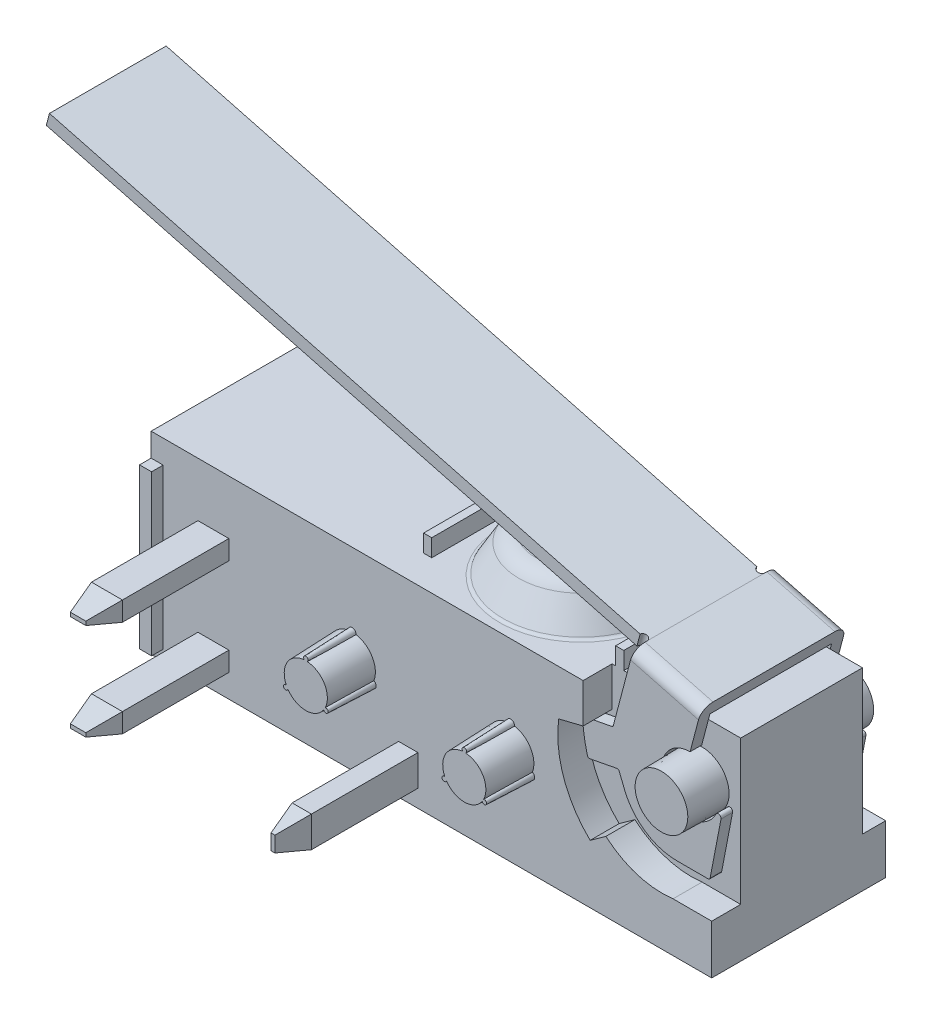
from build123d import *

# Parameters (mm, degrees)
BOSS_EXTRUDE1_DEPTH           = 4.5
BOSS_EXTRUDE3_DEPTH           = 1.2
BOSS_EXTRUDE3_DRAFT           = 2
BOSS_EXTRUDE3_PROFILE_2_DEPTH = 1.2
BOSS_EXTRUDE3_PROFILE_2_DRAFT = 2
SKETCH3_W                     = 0.5
SKETCH3_H                     = 0.8
BOSS_EXTRUDE4_DEPTH           = 3.5
SKETCH3_W_2                   = 0.8
SKETCH3_H_2                   = 0.5
BOSS_EXTRUDE4_2_DEPTH         = 3.5
BOSS_EXTRUDE4_3_DEPTH         = 3.5
CHAMFER1_SIZE                 = 0.2
CHAMFER1_SIZE2                = 0.746410162
CHAMFER2_SIZE                 = 0.2
CHAMFER2_SIZE2                = 0.746410162
CHAMFER3_SIZE                 = 0.2
CHAMFER3_SIZE2                = 0.746410162
CUT_EXTRUDE1_DEPTH            = 0.75
SKETCH6_R                     = 0.7
BOSS_EXTRUDE6_DEPTH           = 1.05
BOSS_EXTRUDE6_TAPER           = 1
CUT_EXTRUDE2_DEPTH            = 0.6
SKETCH8_R                     = 0.7
BOSS_EXTRUDE7_DEPTH           = 0.6
BOSS_EXTRUDE7_TAPER           = 1
SKETCH9_R                     = 2.05
BOSS_EXTRUDE8_DEPTH           = 1
BOSS_EXTRUDE8_TAPER           = 30
FILLET1_R                     = 0.5
FILLET2_R                     = 0.1
SKETCH10_R                    = 0.8
CUT_EXTRUDE3_DEPTH            = 0.2
SKETCH11_R                    = 0.7
BOSS_EXTRUDE9_DEPTH           = 0.4
DOME1_FACE_RADIUS             = 0.7
DOME1_HEIGHT                  = 0.2
SKETCH12_W                    = 0.21
SKETCH12_H                    = 3.15
BOSS_EXTRUDE10_DEPTH          = 0.45
SKETCH14_W                    = 0.311324836
SKETCH14_H                    = 4.124707826
BOSS_EXTRUDE11_DEPTH          = 0.3
BOSS_EXTRUDE12_DEPTH          = 0.3
LPATTERN1_COUNT               = 2
LPATTERN1_PITCH               = 3.45
BOSS_EXTRUDE13_DEPTH          = 3.15
SKETCH18_W                    = 3.75
SKETCH18_H                    = 0.32
BOSS_EXTRUDE14_DEPTH          = 16
CUT_EXTRUDE4_DEPTH            = 0.32
FILLET3_R                     = 0.3


with BuildPart() as part:
    # Sketch1 → Boss-Extrude1 (new body)
    with BuildSketch(Plane.XY):
        Polygon((0, -2.5), (5.2, -2.5), (5.2, 2.5), (-9.3, 2.5), (-9.3, -2.5), align=None)
    extrude(amount=-BOSS_EXTRUDE1_DEPTH)


with BuildPart() as boss_extrude3_tool:
    # Sketch2 → Boss-Extrude3 (with draft: the straight prism first)
    with BuildSketch(Plane.XY):
        with BuildLine():
            ThreePointArc((-0.099652173, 0.591666667), (-0.519615242, 0.3), (-0.56222445, -0.20953202))
            ThreePointArc((-0.56222445, -0.20953202), (-0.606217783, -0.35), (-0.462572277, -0.382134647))
            ThreePointArc((-0.462572277, -0.382134647), (0, -0.6), (0.462572277, -0.382134647))
            ThreePointArc((0.462572277, -0.382134647), (0.606217783, -0.35), (0.56222445, -0.20953202))
            ThreePointArc((0.56222445, -0.20953202), (0.519615242, 0.3), (0.099652173, 0.591666667))
            ThreePointArc((0.099652173, 0.591666667), (0, 0.7), (-0.099652173, 0.591666667))
        make_face()
    extrude(amount=BOSS_EXTRUDE3_DEPTH)
    # Boss-Extrude3: the draft: its side faces are tilted about the plane it starts from
    boss_extrude3_sides = [boss_extrude3_tool.faces().sort_by_distance(p)[0] for p in [
        (0.519615242, 0.3, 0.6),
        (0, 0.7, 0.6),
        (-0.519615242, 0.3, 0.6),
        (-0.606217783, -0.35, 0.6),
        (0, -0.6, 0.6),
        (0.606217783, -0.35, 0.6),
    ]]
    draft(boss_extrude3_sides, Plane.XY, BOSS_EXTRUDE3_DRAFT)


with BuildPart() as part_1:
    add(part.part)

    # Boss-Extrude3: add boss_extrude3_tool
    add(boss_extrude3_tool.part)


with BuildPart() as boss_extrude3_profile_2_tool:
    # Sketch2 → Boss-Extrude3 profile 2 (with draft: the straight prism first)
    with BuildSketch(Plane.XY):
        with BuildLine():
            ThreePointArc((-4.66222445, -0.20953202), (-4.706217783, -0.35), (-4.562572277, -0.382134647))
            ThreePointArc((-4.562572277, -0.382134647), (-4.1, -0.6), (-3.637427723, -0.382134647))
            ThreePointArc((-3.637427723, -0.382134647), (-3.493782217, -0.35), (-3.53777555, -0.20953202))
            ThreePointArc((-3.53777555, -0.20953202), (-3.580384758, 0.3), (-4.000347827, 0.591666667))
            ThreePointArc((-4.000347827, 0.591666667), (-4.1, 0.7), (-4.199652173, 0.591666667))
            ThreePointArc((-4.199652173, 0.591666667), (-4.619615242, 0.3), (-4.66222445, -0.20953202))
        make_face()
    extrude(amount=BOSS_EXTRUDE3_PROFILE_2_DEPTH)
    # Boss-Extrude3 profile 2: the draft: its side faces are tilted about the plane it starts from
    boss_extrude3_profile_2_sides = [boss_extrude3_profile_2_tool.faces().sort_by_distance(p)[0] for p in [
        (-4.1, 0.7, 0.6),
        (-4.619615242, 0.3, 0.6),
        (-4.706217783, -0.35, 0.6),
        (-4.1, -0.6, 0.6),
        (-3.493782217, -0.35, 0.6),
        (-3.580384758, 0.3, 0.6),
    ]]
    draft(boss_extrude3_profile_2_sides, Plane.XY, BOSS_EXTRUDE3_PROFILE_2_DRAFT)


with BuildPart() as part_2:
    add(part_1.part)

    # Boss-Extrude3 profile 2: add boss_extrude3_profile_2_tool
    add(boss_extrude3_profile_2_tool.part)

    # Sketch5 → Cut-Extrude1 (cut)
    with BuildSketch(Plane.XY):
        with BuildLine():
            Line((5.2, 2.5), (1.873674348, 2.5))
            Line((1.873674348, 2.5), (1.873674348, 1.481625468))
            Line((1.873674348, 1.481625468), (1.241954315, 1.325609641))
            ThreePointArc((1.241954315, 1.325609641), (1.37112217, 0.071098566), (2.055446922, -0.988232357))
            Line((2.055446922, -0.988232357), (2.46319838, -0.695622678))
            ThreePointArc((2.46319838, -0.695622678), (3.274611315, -1.147475163), (4.2, -1.226325652))
            Line((4.2, -1.226325652), (5.2, -1.226325652))
            Line((5.2, -1.226325652), (5.2, 2.5))
        make_face()
    extrude(amount=-CUT_EXTRUDE1_DEPTH, mode=Mode.SUBTRACT)

    # Sketch6 → Boss-Extrude6 (add)
    with BuildSketch(Plane.XY.offset(-0.75)):
        with Locations((4.2, 1.1)):
            Circle(SKETCH6_R)
    extrude(amount=BOSS_EXTRUDE6_DEPTH, taper=BOSS_EXTRUDE6_TAPER)

    # Sketch7 → Cut-Extrude2 (cut)
    with BuildSketch(Plane(origin=(0, 0, -4.5), x_dir=(-1, 0, 0), z_dir=(0, 0, -1))):
        with BuildLine():
            Line((-1.274940789, 1.291908081), (-1.873674348, 1.453118443))
            Line((-1.873674348, 1.453118443), (-1.873674348, 2.5))
            Line((-1.873674348, 2.5), (-5.2, 2.5))
            Line((-5.2, 2.5), (-5.2, -1.226325652))
            Line((-5.2, -1.226325652), (-4.2, -1.226325652))
            ThreePointArc((-4.2, -1.226325652), (-3.274611315, -1.147475163), (-2.46319838, -0.695622678))
            Line((-2.46319838, -0.695622678), (-2.086048236, -0.966272312))
            ThreePointArc((-2.086048236, -0.966272312), (-1.41206126, 0.06640034), (-1.274940789, 1.291908081))
        make_face()
    extrude(amount=-CUT_EXTRUDE2_DEPTH, mode=Mode.SUBTRACT)

    # Sketch8 → Boss-Extrude7 (add)
    with BuildSketch(Plane(origin=(0, 0, -3.9), x_dir=(-1, 0, 0), z_dir=(0, 0, -1))):
        with Locations((-4.2, 1.1)):
            Circle(SKETCH8_R)
    extrude(amount=BOSS_EXTRUDE7_DEPTH, taper=BOSS_EXTRUDE7_TAPER)

    # Sketch9 → Boss-Extrude8 (add)
    with BuildSketch(Plane(origin=(0, 2.5, 0), x_dir=(1, 0, 0), z_dir=(0, 1, 0))):
        with Locations((-0.5, 2.325)):
            Circle(SKETCH9_R)
    extrude(amount=BOSS_EXTRUDE8_DEPTH, taper=BOSS_EXTRUDE8_TAPER)

    # Fillet1
    fillet1_edges = [part_2.edges().sort_by_distance(p)[0] for p in [
        (-1.972649731, 3.5, -2.325),
    ]]
    fillet(fillet1_edges, radius=FILLET1_R)

    # Fillet2
    fillet2_edges = [part_2.edges().sort_by_distance(p)[0] for p in [
        (-2.55, 2.5, -2.325),
    ]]
    fillet(fillet2_edges, radius=FILLET2_R)

    # Sketch10 → Cut-Extrude3 (cut)
    with BuildSketch(Plane(origin=(0, 3.5, 0), x_dir=(1, 0, 0), z_dir=(0, 1, 0))):
        with Locations(Location((-0.5, 2.325, 0), (0, 0, 180))):
            Circle(SKETCH10_R)
    extrude(amount=-CUT_EXTRUDE3_DEPTH, mode=Mode.SUBTRACT)

    # Sketch11 → Boss-Extrude9 (add)
    with BuildSketch(Plane(origin=(0, 3.3, 0), x_dir=(1, 0, 0), z_dir=(0, 1, 0))):
        with Locations(Location((-0.5, 2.325, 0), (0, 0, 180))):
            Circle(SKETCH11_R)
    extrude(amount=BOSS_EXTRUDE9_DEPTH)

    # Dome1: a dome of height H over a round flat face of radius A is a cap of a sphere of radius (A * A + H * H) / (2 * H)
    dome1_r = (DOME1_FACE_RADIUS * DOME1_FACE_RADIUS + DOME1_HEIGHT * DOME1_HEIGHT) / (2 * DOME1_HEIGHT)
    dome1_base = Plane((-0.5, 3.7, -2.325), z_dir=(0, 1, 0))
    with Locations(dome1_base.offset(DOME1_HEIGHT - dome1_r)):
        dome1_ball = Sphere(dome1_r, mode=Mode.PRIVATE)
    add(split(dome1_ball, bisect_by=dome1_base, keep=Keep.TOP, mode=Mode.PRIVATE))

    # Sketch12 → Boss-Extrude10 (add)
    with BuildSketch(Plane(origin=(0, 2.5, 0), x_dir=(1, 0, 0), z_dir=(0, 1, 0))):
        with Locations((2.07034832, 2.325)):
            Rectangle(SKETCH12_W, SKETCH12_H)
        with Locations((-2.93965168, 2.366987298)):
            Rectangle(SKETCH12_W, SKETCH12_H)
    extrude(amount=BOSS_EXTRUDE10_DEPTH)

    # Sketch14 → Boss-Extrude11 (add)
    with BuildSketch(Plane.XY):
        with Locations((-9.144337582, -0.166601739)):
            Rectangle(SKETCH14_W, SKETCH14_H)
    extrude(amount=BOSS_EXTRUDE11_DEPTH)


with BuildPart() as body_2:
    # Sketch3 → Boss-Extrude4 (new body)
    with BuildSketch(Plane.XY):
        with Locations((-2.65, -1.65)):
            Rectangle(SKETCH3_W, SKETCH3_H)
    extrude(amount=BOSS_EXTRUDE4_DEPTH)

    # Chamfer1
    chamfer1_edges = [body_2.edges().sort_by_distance(p)[0] for p in [
        (-2.4, -1.65, 3.5),
        (-2.65, -1.25, 3.5),
        (-2.9, -1.65, 3.5),
        (-2.65, -2.05, 3.5),
    ]]
    chamfer1_side = [body_2.faces().sort_by_distance(p)[0] for p in [
        (-2.65, -1.65, 3.5),
    ]]
    chamfer(chamfer1_edges, length=CHAMFER1_SIZE, length2=CHAMFER1_SIZE2, reference=chamfer1_side[0])


with BuildPart() as body_3:
    # Sketch3 → Boss-Extrude4 2 (new body)
    with BuildSketch(Plane.XY):
        with Locations((-7.69, -1.65)):
            Rectangle(SKETCH3_W_2, SKETCH3_H_2)
    extrude(amount=BOSS_EXTRUDE4_2_DEPTH)

    # Chamfer3
    chamfer3_edges = [body_3.edges().sort_by_distance(p)[0] for p in [
        (-7.69, -1.4, 3.5),
        (-8.09, -1.65, 3.5),
        (-7.69, -1.9, 3.5),
        (-7.29, -1.65, 3.5),
    ]]
    chamfer3_side = [body_3.faces().sort_by_distance(p)[0] for p in [
        (-7.69, -1.65, 3.5),
    ]]
    chamfer(chamfer3_edges, length=CHAMFER3_SIZE, length2=CHAMFER3_SIZE2, reference=chamfer3_side[0])


with BuildPart() as body_4:
    # Sketch3 → Boss-Extrude4 3 (new body)
    with BuildSketch(Plane.XY):
        with Locations((-7.69, 0.85)):
            Rectangle(SKETCH3_W_2, SKETCH3_H_2)
    extrude(amount=BOSS_EXTRUDE4_3_DEPTH)

    # Chamfer2
    chamfer2_edges = [body_4.edges().sort_by_distance(p)[0] for p in [
        (-7.69, 1.1, 3.5),
        (-8.09, 0.85, 3.5),
        (-7.69, 0.6, 3.5),
        (-7.29, 0.85, 3.5),
    ]]
    chamfer2_side = [body_4.faces().sort_by_distance(p)[0] for p in [
        (-7.69, 0.85, 3.5),
    ]]
    chamfer(chamfer2_edges, length=CHAMFER2_SIZE, length2=CHAMFER2_SIZE2, reference=chamfer2_side[0])


with BuildPart() as body_5:
    # Sketch16 → Boss-Extrude12 (new body)
    with BuildSketch(Plane(origin=(0, 0, -3.9), x_dir=(-1, 0, 0), z_dir=(0, 0, -1))):
        with BuildLine():
            Line((-2.72663653, 3.413925414), (-2.695824269, 3.296907977))
            Line((-2.695824269, 3.296907977), (-2.488472864, 2.50943572))
            Line((-2.488472864, 2.50943572), (-2.20425473, 1.430051227))
            ThreePointArc((-2.20425473, 1.430051227), (-2.189921217, 1.406051159), (-2.165005418, 1.39337615))
            Line((-2.165005418, 1.39337615), (-1.447969658, 1.255711923))
            ThreePointArc((-1.447969658, 1.255711923), (-1.417524264, 1.236952921), (-1.407177653, 1.202721797))
            ThreePointArc((-1.407177653, 1.202721797), (-1.45311078, 0.809028192), (-1.53591297, 0.421409431))
            ThreePointArc((-1.53591297, 0.421409431), (-1.557811612, 0.391583969), (-1.594174631, 0.384740023))
            Line((-1.594174631, 0.384740023), (-2.299234869, 0.520103434))
            ThreePointArc((-2.299234869, 0.520103434), (-2.3328806, 0.514852457), (-2.35551456, 0.489410133))
            Line((-2.35551456, 0.489410133), (-2.495754598, 0.140912844))
            ThreePointArc((-2.495754598, 0.140912844), (-3.031478288, -0.524518255), (-3.848195145, -0.775061653))
            Line((-3.848195145, -0.775061653), (-4.65874421, -0.775061653))
            ThreePointArc((-4.65874421, -0.775061653), (-4.690850708, -0.763517251), (-4.708254225, -0.734170735))
            Line((-4.708254225, -0.734170735), (-4.990094107, 0.730319368))
            ThreePointArc((-4.990094107, 0.730319368), (-4.951140876, 0.8081036), (-4.865921819, 0.790626376))
            ThreePointArc((-4.865921819, 0.790626376), (-3.568066632, 0.696612208), (-4.191345891, 1.838886132))
            Line((-4.191345891, 1.838886132), (-4.367910647, 2.509435719))
            Line((-4.367910647, 2.509435719), (-4.484213486, 2.951129352))
            Line((-4.484213486, 2.951129352), (-2.72663653, 3.413925414))
        make_face()
    boss_extrude12 = extrude(amount=BOSS_EXTRUDE12_DEPTH)


with BuildPart() as part_3:
    add(part_2.part)

    # LPattern1: Boss-Extrude12 ×2
    with Locations(*[(0, 0, i * LPATTERN1_PITCH) for i in range(1, LPATTERN1_COUNT)]):
        add(boss_extrude12)

    add(body_5.part)  # Boss-Extrude13 merges body 5
    # Sketch17 → Boss-Extrude13 (add)
    with BuildSketch(Plane.XY.offset(-3.9)):
        Polygon((2.72663653, 3.413925414), (4.484213486, 2.951129352), (4.402730622, 2.641677348), (2.645153666, 3.10447341), align=None)
    extrude(amount=BOSS_EXTRUDE13_DEPTH)

    # Sketch18 → Boss-Extrude14 (add)
    with BuildSketch(Plane(origin=(1.709198667, -0.450054938, 0), x_dir=(0, 0, 1), z_dir=(-0.9670375129380588, 0.25463395015310475, 0))):
        with Locations((-2.325, 3.835688172)):
            Rectangle(SKETCH18_W, SKETCH18_H)
    extrude(amount=BOSS_EXTRUDE14_DEPTH)

    # Sketch22 → Cut-Extrude4 (cut)
    with BuildSketch(Plane(origin=(1.017437863, 3.863980352, 0), x_dir=(0.9670375129380588, -0.2546339501531047, 0), z_dir=(0.2546339501531047, 0.9670375129380588, 0))):
        with BuildLine():
            Line((1.767458495, 0.45), (1.767458495, 0.815572262))
            ThreePointArc((1.767458495, 0.815572262), (1.667172364, 0.901333375), (1.566886233, 0.815572262))
            Line((1.566886233, 0.815572262), (-14.232541505, 0.815572262))
            Line((-14.232541505, 0.815572262), (-14.232541505, 0.45))
            Line((-14.232541505, 0.45), (1.767458495, 0.45))
        make_face()
        with BuildLine():
            Line((1.767458495, 4.2), (1.767458495, 3.834427738))
            ThreePointArc((1.767458495, 3.834427738), (1.667172364, 3.748666625), (1.567457676, 3.834427738))
            Line((1.567457676, 3.834427738), (-14.232541505, 3.834427738))
            Line((-14.232541505, 3.834427738), (-14.232541505, 4.2))
            Line((-14.232541505, 4.2), (1.767458495, 4.2))
        make_face()
    extrude(amount=-CUT_EXTRUDE4_DEPTH, mode=Mode.SUBTRACT)

    # Fillet3
    fillet3_edges = [part_3.edges().sort_by_distance(p)[0] for p in [
        (3.605425008, 3.182527383, -4.2),
        (3.605425008, 3.182527383, -0.45),
    ]]
    fillet(fillet3_edges, radius=FILLET3_R)


solid = Compound([body_2.part, body_3.part, body_4.part, part_3.part])
